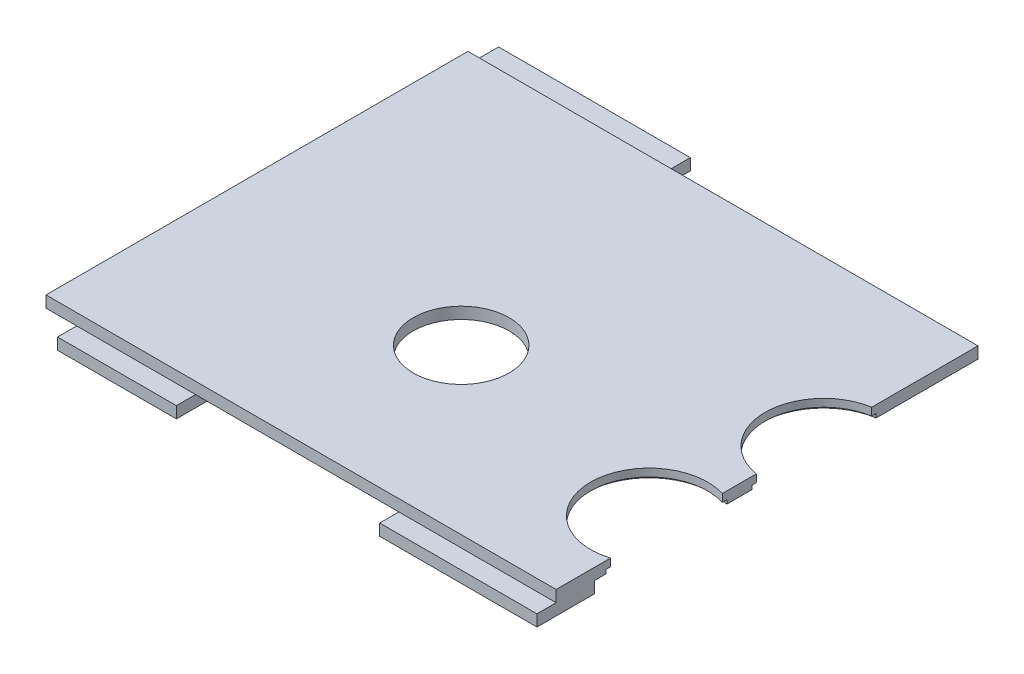
from build123d import *

# Parameters (mm, degrees)
SKETCH1_W           = 133
SKETCH1_H           = 110
BOSS_EXTRUDE1_DEPTH = 3
SKETCH2_W           = 50
SKETCH2_H           = 18
SKETCH2_W_2         = 41
SKETCH2_H_2         = 15
SKETCH2_W_3         = 31
BOSS_EXTRUDE2_DEPTH = 3
CUT_EXTRUDE1_REACH  = 8
SKETCH3_R           = 12.5
SKETCH3_R_2         = 15.25
SKETCH4_R           = 16.375
CUT_EXTRUDE2_DEPTH  = 1


with BuildPart() as part:
    # Sketch1 → Boss-Extrude1 (new body)
    with BuildSketch(Plane(origin=(0, 0, 0), x_dir=(1, 0, 0), z_dir=(0, 1, 0))):
        with Locations((66.5, 55)):
            Rectangle(SKETCH1_W, SKETCH1_H)
    extrude(amount=BOSS_EXTRUDE1_DEPTH)

    # Sketch2 → Boss-Extrude2 (add)
    with BuildSketch(Plane.XZ):
        with Locations((25, -109)):
            Rectangle(SKETCH2_W, SKETCH2_H)
        with Locations((112.5, -2.5)):
            Rectangle(SKETCH2_W_2, SKETCH2_H_2)
        with Locations((23.5, -2.5)):
            Rectangle(SKETCH2_W_3, SKETCH2_H_2)
    extrude(amount=BOSS_EXTRUDE2_DEPTH)

    # Sketch3 → Cut-Extrude1 (cut, up to next)
    with BuildSketch(Plane(origin=(0, 3, 0), x_dir=(1, 0, 0), z_dir=(0, 1, 0)), mode=Mode.PRIVATE) as cut_extrude1_sk1:
        with Locations((65.5, 42.75)):
            Circle(SKETCH3_R)
    cut_extrude1_tool1 = extrude(cut_extrude1_sk1.sketch, amount=-CUT_EXTRUDE1_REACH, mode=Mode.PRIVATE) & part.part
    add(cut_extrude1_tool1.solids().sort_by_distance((65.5, 3, -42.75))[0], mode=Mode.SUBTRACT)
    # Sketch3 → Cut-Extrude1 (cut, up to next)
    with BuildSketch(Plane(origin=(0, 3, 0), x_dir=(1, 0, 0), z_dir=(0, 1, 0)), mode=Mode.PRIVATE) as cut_extrude1_sk2:
        with Locations((128.5, 28.75)):
            Circle(SKETCH3_R_2)
    cut_extrude1_tool2 = extrude(cut_extrude1_sk2.sketch, amount=-CUT_EXTRUDE1_REACH, mode=Mode.PRIVATE) & part.part
    add(cut_extrude1_tool2.solids().sort_by_distance((128.5, 3, -28.75))[0], mode=Mode.SUBTRACT)
    # Sketch3 → Cut-Extrude1 (cut, up to next)
    with BuildSketch(Plane(origin=(0, 3, 0), x_dir=(1, 0, 0), z_dir=(0, 1, 0)), mode=Mode.PRIVATE) as cut_extrude1_sk3:
        with Locations((135.5, 67.25)):
            Circle(SKETCH3_R_2)
    cut_extrude1_tool3 = extrude(cut_extrude1_sk3.sketch, amount=-CUT_EXTRUDE1_REACH, mode=Mode.PRIVATE) & part.part
    add(cut_extrude1_tool3.solids().sort_by_distance((135.5, 3, -67.25))[0], mode=Mode.SUBTRACT)

    # Sketch4 → Cut-Extrude2 (cut)
    with BuildSketch(Plane.XZ):
        with Locations((128.5, -28.75)):
            Circle(SKETCH4_R)
        with Locations((135.5, -67.25)):
            Circle(SKETCH4_R)
    extrude(amount=-CUT_EXTRUDE2_DEPTH, mode=Mode.SUBTRACT)


solid = part.part
